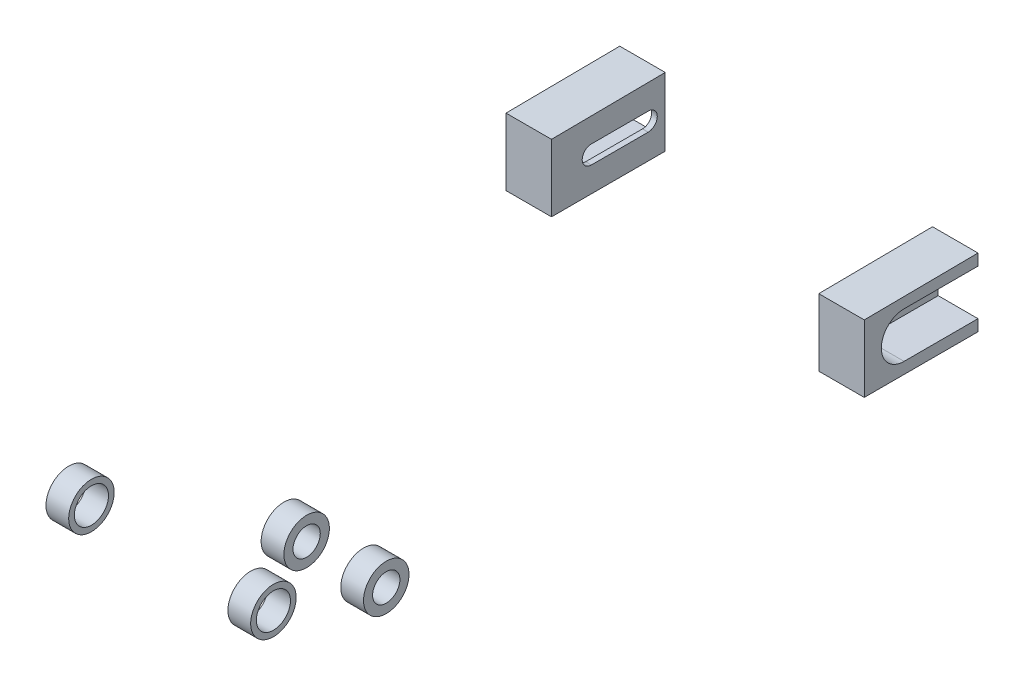
from build123d import *

# Parameters (mm, degrees)
TYLNE_START              = -7.5
TYLNE_KO_O_DEPTH         = 5
TYLENE_START             = -2.5
TYLENE_KO_O_2_DEPTH      = 35
RAMA_START               = -55
SZKIC_INSERT_RAMA_R      = 20
SZKIC_INSERT_RAMA_R_2    = 15
RAMA_DEPTH               = 10
LINKAGE_START            = 25
SZKIC_INSERT_LINKAGE_R   = 20
SZKIC_INSERT_LINKAGE_R_2 = 12
LINKAGE_DEPTH            = 20


with BuildPart() as part:
    # Szkic - insert - tylne koło → Tylne koło (new body)
    with BuildSketch(Plane(origin=(125, 0, 0), x_dir=(0, 0, -1), z_dir=(1, 0, 0)).offset(TYLNE_START)):
        with BuildLine():
            ThreePointArc((487, 20), (467, 0), (487, -20))
            Line((487, -20), (552, -20))
            Line((552, -20), (552, -30))
            Line((552, -30), (452, -30))
            Line((452, -30), (452, 29.044549731))
            Line((452, 29.044549731), (552, 30))
            Line((552, 30), (552, 20))
            Line((552, 20), (487, 20))
        make_face()
        with BuildLine():
            Line((487, 20), (552, 20))
            Line((552, 20), (552, -20))
            Line((552, -20), (487, -20))
            ThreePointArc((487, -20), (467, 0), (487, 20))
        make_face()
        with BuildLine():
            ThreePointArc((537, -8), (545, 0), (537, 8))
            Line((537, 8), (487, 8))
            ThreePointArc((487, 8), (479, 0), (487, -8))
            Line((487, -8), (537, -8))
        make_face(mode=Mode.SUBTRACT)
    extrude(amount=TYLNE_KO_O_DEPTH)

    # Szkic - insert - tylne koło<6> → Tylene koło 2 (add)
    with BuildSketch(Plane(origin=(125, 0, 0), x_dir=(0, 0, -1), z_dir=(1, 0, 0)).offset(TYLENE_START)):
        with BuildLine():
            ThreePointArc((487, 20), (467, 0), (487, -20))
            Line((487, -20), (552, -20))
            Line((552, -20), (552, -30))
            Line((552, -30), (452, -30))
            Line((452, -30), (452, 29.044549731))
            Line((452, 29.044549731), (552, 30))
            Line((552, 30), (552, 20))
            Line((552, 20), (487, 20))
        make_face()
    extrude(amount=TYLENE_KO_O_2_DEPTH)


with BuildPart() as body_2:
    # Szkic - insert - rama → Rama (new, symmetric)
    with BuildSketch(Plane(origin=(135, 0, 0), x_dir=(0, 0, -1), z_dir=(1, 0, 0)).offset(RAMA_START)):
        Circle(SZKIC_INSERT_RAMA_R)
        Circle(SZKIC_INSERT_RAMA_R_2, mode=Mode.SUBTRACT)
    extrude(amount=RAMA_DEPTH, both=True)


with BuildPart() as body_3:
    # Szkic - insert - linkage → Linkage (new body)
    with BuildSketch(Plane(origin=(0, 0, 0), x_dir=(0, 0, -1), z_dir=(1, 0, 0)).offset(LINKAGE_START)):
        with Locations((144.2, -77)):
            Circle(SZKIC_INSERT_LINKAGE_R)
        with Locations((144.2, -77)):
            Circle(SZKIC_INSERT_LINKAGE_R_2, mode=Mode.SUBTRACT)
    extrude(amount=LINKAGE_DEPTH)


with BuildPart() as body_4:
    # Lustro1: mirrored copy
    add(part.part.mirror(Plane(origin=(0, 0, 0), x_dir=(0, 0, 1), z_dir=(1, 0, 0))))


with BuildPart() as body_5:
    # Lustro1 2: mirrored copy
    add(body_2.part.mirror(Plane(origin=(0, 0, 0), x_dir=(0, 0, 1), z_dir=(1, 0, 0))))


with BuildPart() as body_6:
    # Lustro1 3: mirrored copy
    add(body_3.part.mirror(Plane(origin=(0, 0, 0), x_dir=(0, 0, 1), z_dir=(1, 0, 0))))


solid = Compound([part.part, body_2.part, body_3.part, body_4.part, body_5.part, body_6.part])
